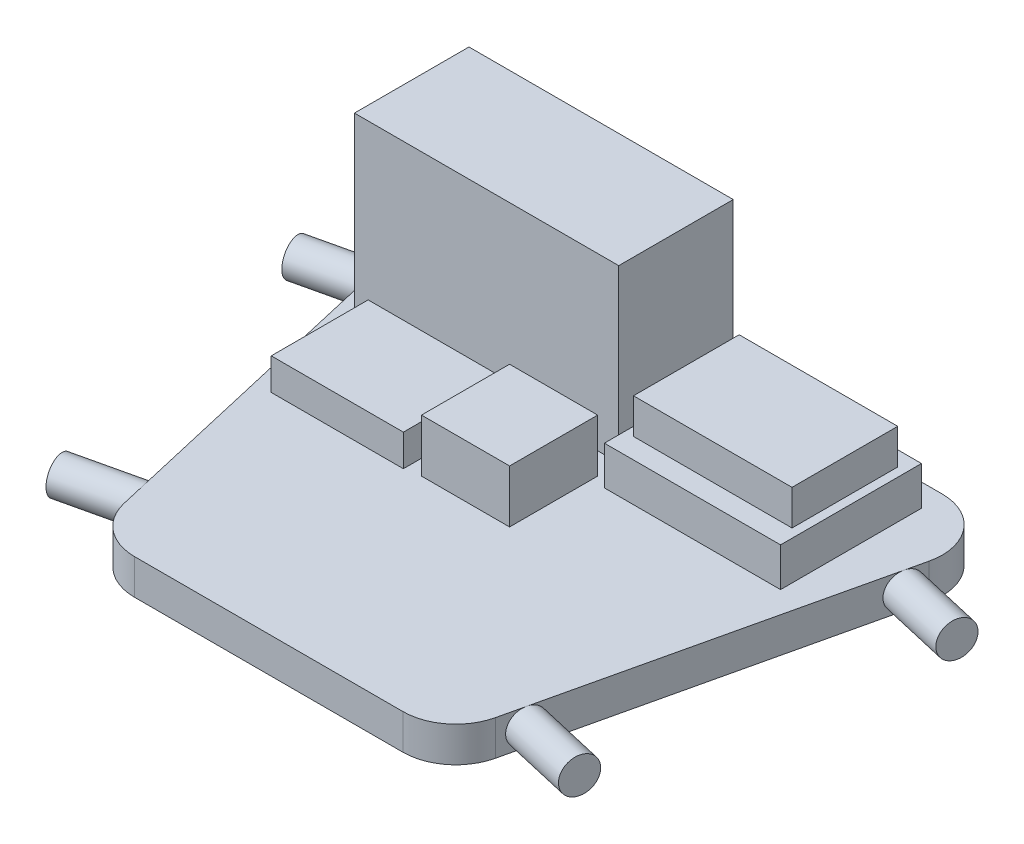
from build123d import *

# Parameters (mm, degrees)
BOSS_EXTRUDE1_DEPTH = 20
SKETCH2_W           = 150
SKETCH2_H           = 65
BOSS_EXTRUDE2_DEPTH = 97
SKETCH4_W           = 100
SKETCH4_H           = 80
BOSS_EXTRUDE3_DEPTH = 22
SKETCH5_W           = 90
SKETCH5_H           = 60
BOSS_EXTRUDE4_DEPTH = 20
SKETCH7_W           = 75
SKETCH7_H           = 55
BOSS_EXTRUDE5_DEPTH = 18
SKETCH9_W           = 50
SKETCH9_H           = 50
BOSS_EXTRUDE6_DEPTH = 30
SKETCH10_R          = 10
BOSS_EXTRUDE7_DEPTH = 40


with BuildPart() as part:
    # Sketch1 → Boss-Extrude1 (new body)
    with BuildSketch(Plane(origin=(0, 0, 0), x_dir=(1, 0, 0), z_dir=(0, 1, 0))):
        with BuildLine():
            Line((-122.288467544, 114.797617793), (122.288467544, 114.797617793))
            ThreePointArc((122.288467544, 114.797617793), (145.765834901, 103.474159817), (151.520203415, 78.051832592))
            Line((151.520203415, 78.051832592), (105.366357261, -121.948167408))
            ThreePointArc((105.366357261, -121.948167408), (94.811163415, -138.679749564), (76.13462139, -145.202382207))
            Line((76.13462139, -145.202382207), (-76.13462139, -145.202382207))
            ThreePointArc((-76.13462139, -145.202382207), (-94.811163415, -138.679749564), (-105.366357261, -121.948167408))
            Line((-105.366357261, -121.948167408), (-151.520203415, 78.051832592))
            ThreePointArc((-151.520203415, 78.051832592), (-145.765834901, 103.474159817), (-122.288467544, 114.797617793))
        make_face()
    extrude(amount=-BOSS_EXTRUDE1_DEPTH)

    # Sketch2 → Boss-Extrude2 (add)
    with BuildSketch(Plane(origin=(0, 0, 0), x_dir=(1, 0, 0), z_dir=(0, 1, 0))):
        with Locations((-59.803637432, 70.737817799)):
            Rectangle(SKETCH2_W, SKETCH2_H)
    extrude(amount=BOSS_EXTRUDE2_DEPTH)

    # Sketch4 → Boss-Extrude3 (add)
    with BuildSketch(Plane(origin=(0, 0, 0), x_dir=(1, 0, 0), z_dir=(0, 1, 0))):
        with Locations((73.379228632, 61.908908542)):
            Rectangle(SKETCH4_W, SKETCH4_H)
    extrude(amount=BOSS_EXTRUDE3_DEPTH)

    # Sketch5 → Boss-Extrude4 (add)
    with BuildSketch(Plane(origin=(0, 22, 0), x_dir=(1, 0, 0), z_dir=(0, 1, 0))):
        with Locations((73.353532596, 63.452591803)):
            Rectangle(SKETCH5_W, SKETCH5_H)
    extrude(amount=BOSS_EXTRUDE4_DEPTH)

    # Sketch7 → Boss-Extrude5 (add)
    with BuildSketch(Plane(origin=(0, 0, 0), x_dir=(1, 0, 0), z_dir=(0, 1, 0))):
        with Locations((-80.583724221, 1.784070664)):
            Rectangle(SKETCH7_W, SKETCH7_H)
    extrude(amount=BOSS_EXTRUDE5_DEPTH)

    # Sketch9 → Boss-Extrude6 (add)
    with BuildSketch(Plane(origin=(0, 0, 0), x_dir=(1, 0, 0), z_dir=(0, 1, 0))):
        with Locations((-9.322697354, 0.802057889)):
            Rectangle(SKETCH9_W, SKETCH9_H)
    extrude(amount=BOSS_EXTRUDE6_DEPTH)

    # Sketch10 → Boss-Extrude7 (add)
    with BuildSketch(Plane(origin=(-126.757825315, 0, 29.251805842), x_dir=(0.22485950669875854, 0, 0.97439119569462), z_dir=(-0.97439119569462, 0, 0.22485950669875854))):
        with Locations((80.281358312, -9.946535293)):
            Circle(SKETCH10_R)
        with Locations((-98.316139362, -9.946535293)):
            Circle(SKETCH10_R)
    boss_extrude7 = extrude(amount=BOSS_EXTRUDE7_DEPTH)

    # Mirror6: Boss-Extrude7 across plane
    add(boss_extrude7.mirror(Plane(origin=(0, 0, 0), x_dir=(0, 0, 1), z_dir=(1, 0, 0))))


solid = part.part
